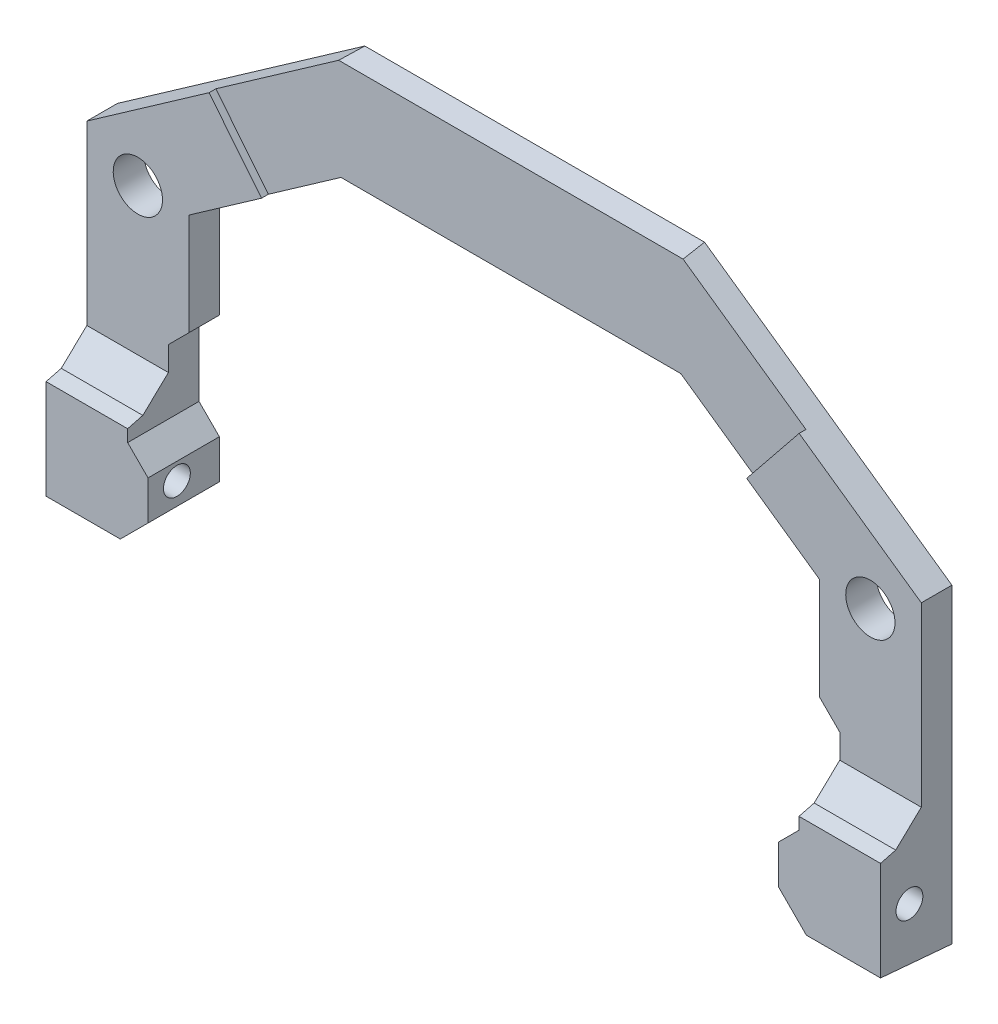
from build123d import *

# Parameters (mm, degrees)
BOSS_EXTRUDE1_DEPTH                  = 6.35
CUT_START                            = -8.62
SKETCH2_R                            = 1.0033
CUT_FOR_LID_MOUNT_SCREW_DEPTH        = 33.1912
SKETCH3_R                            = 1.8415
CUT_FOR_MOUNTING_SCREW_DEPTH         = 7.35
CUT_FOR_CONTROL_WIRE_CLEARANCE_DEPTH = 7.35
BOSS_EXTRUDE2_DEPTH                  = 6.35
CUT_EXTRUDE1_DEPTH                   = 7.35
CUT_EXTRUDE2_DEPTH                   = 63.3824
SKETCH18_W                           = 1.016
SKETCH18_H                           = 8.944323542
CUT_EXTRUDE11_DEPTH                  = 63.3824
CUT_EXTRUDE12_DEPTH                  = 0.508


with BuildPart() as part:
    # Sketch1 → Boss-Extrude1 (new body)
    with BuildSketch(Plane.XY):
        Polygon((0, 0), (-31.1912, 0), (-31.1912, -36.195), (-23.5712, -36.195), (-23.5712, -7.62), (0, -7.62), align=None)
    boss_extrude1 = extrude(amount=BOSS_EXTRUDE1_DEPTH)

    # Sketch2 → cut for lid mount screw (cut)
    with BuildSketch(Plane(origin=(-23.5712, 0, 0), x_dir=(0, 0, -1), z_dir=(1, 0, 0)).offset(CUT_START)):
        with Locations((-3.175, -32.004)):
            Circle(SKETCH2_R)
    cut_for_lid_mount_screw = extrude(amount=CUT_FOR_LID_MOUNT_SCREW_DEPTH, mode=Mode.SUBTRACT)

    # Sketch3 → cut for mounting screw (cut, through all)
    with BuildSketch(Plane.XY.offset(6.35)):
        with Locations((-27.3812, -15.24)):
            Circle(SKETCH3_R)
    cut_for_mounting_screw = extrude(amount=-CUT_FOR_MOUNTING_SCREW_DEPTH, mode=Mode.SUBTRACT)

    # Mirror1: Boss-Extrude1 across plane
    add(boss_extrude1.mirror(Plane(origin=(0, 0, 0), x_dir=(0, 0, 1), z_dir=(1, 0, 0))))

    # Mirror2: cut for lid mount screw across plane
    add(cut_for_lid_mount_screw.mirror(Plane(origin=(0, 0, 0), x_dir=(0, 0, 1), z_dir=(1, 0, 0))), mode=Mode.SUBTRACT)

    # Mirror3: cut for mounting screw across plane
    add(cut_for_mounting_screw.mirror(Plane(origin=(0, 0, 0), x_dir=(0, 0, 1), z_dir=(1, 0, 0))), mode=Mode.SUBTRACT)

    # Sketch4 → cut for control wire clearance (cut, through all)
    with BuildSketch(Plane.XY.offset(6.35)):
        Polygon((-25.0952, -24.384), (-25.0952, -29.207906516), (-23.5712, -30.731906516), (-23.5712, -22.86), align=None)
        Polygon((-23.5712, -36.195), (-23.5712, -33.655), (-26.1112, -36.195), align=None)
    cut_for_control_wire_clearance = extrude(amount=-CUT_FOR_CONTROL_WIRE_CLEARANCE_DEPTH, mode=Mode.SUBTRACT)

    # Mirror4: cut for control wire clearance across plane
    add(cut_for_control_wire_clearance.mirror(Plane(origin=(0, 0, 0), x_dir=(0, 0, 1), z_dir=(1, 0, 0))), mode=Mode.SUBTRACT)

    # Sketch5 → Boss-Extrude2 (add)
    with BuildSketch(Plane.XY.offset(6.35)):
        Polygon((-23.5712, -15.24), (-12.7, -7.62), (-13.297814932, 0), (-31.1912, -12.542092337), (-25.168706666, -12.542092337), align=None)
    boss_extrude2 = extrude(amount=-BOSS_EXTRUDE2_DEPTH)

    # Sketch6 → Cut-Extrude1 (cut, through all)
    with BuildSketch(Plane.XY.offset(6.35)):
        Polygon((-12.7, 0), (-31.1912, -12.961121495), (-31.1912, 0), align=None)
    cut_extrude1 = extrude(amount=-CUT_EXTRUDE1_DEPTH, mode=Mode.SUBTRACT)

    # Mirror5: Boss-Extrude2, Cut-Extrude1 across plane
    add(boss_extrude2.mirror(Plane(origin=(0, 0, 0), x_dir=(0, 0, 1), z_dir=(1, 0, 0))))
    add(cut_extrude1.mirror(Plane(origin=(0, 0, 0), x_dir=(0, 0, 1), z_dir=(1, 0, 0))), mode=Mode.SUBTRACT)

    # Sketch7 → Cut-Extrude2 (cut, through all)
    with BuildSketch(Plane.ZY.offset(31.1912)):
        Polygon((6.35, -28.575), (4.201541935, -28.012372807), (2.286, -26.197127086), (2.286, -0.156208848), (0, 0), (6.35, 0), align=None)
        Polygon((0, -36.195), (6.35, -36.195), (6.35, -35.639446987), align=None)
    extrude(amount=-CUT_EXTRUDE2_DEPTH, mode=Mode.SUBTRACT)

    # Sketch18 → Cut-Extrude11 (cut, through all)
    with BuildSketch(Plane(origin=(31.1912, 0, 0), x_dir=(0, 0, -1), z_dir=(1, 0, 0))):
        with Locations((-5.842, -31.986995599)):
            Rectangle(SKETCH18_W, SKETCH18_H)
    extrude(amount=-CUT_EXTRUDE11_DEPTH, mode=Mode.SUBTRACT)

    # Sketch19 → Cut-Extrude12 (cut)
    with BuildSketch(Plane.XY.offset(2.286)):
        Polygon((-22.057028978, -6.558665171), (-18.1356, -11.43), (-12.7, -7.62), (0, -7.62), (0, 0), (-12.7, 0), align=None)
    cut_extrude12 = extrude(amount=-CUT_EXTRUDE12_DEPTH, mode=Mode.SUBTRACT)

    # Mirror6: Cut-Extrude12 across plane
    add(cut_extrude12.mirror(Plane(origin=(0, 0, 0), x_dir=(0, 0, 1), z_dir=(1, 0, 0))), mode=Mode.SUBTRACT)


solid = part.part
